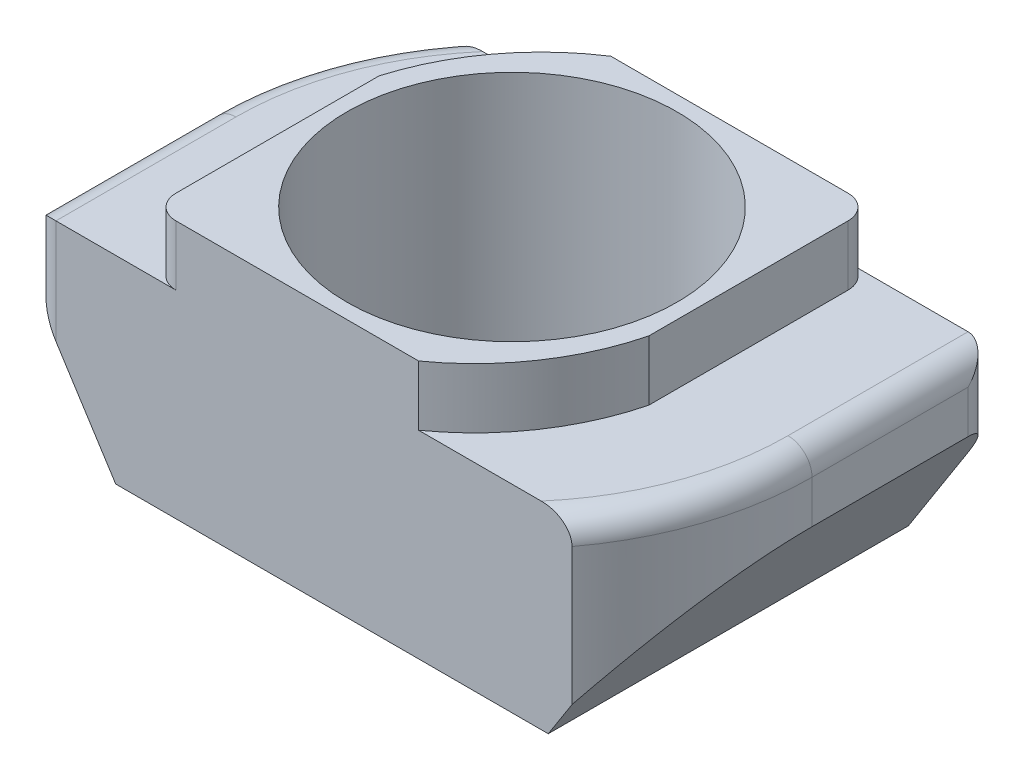
from build123d import *

# Parameters (mm, degrees)
BOSS_EXTRUDE1_DEPTH = 3.3
BOSS_EXTRUDE2_DEPTH = 1
SKETCH4_R           = 2.75
CUT_EXTRUDE1_DEPTH  = 5.3
CUT_EXTRUDE2_DEPTH  = 7
FILLET1_R           = 0.4


with BuildPart() as part:
    # Sketch1 → Boss-Extrude1 (new body)
    with BuildSketch(Plane(origin=(0, 0, 0), x_dir=(1, 0, 0), z_dir=(0, 1, 0))):
        with BuildLine():
            Line((-5, -3), (4, -3))
            ThreePointArc((4, -3), (4.74341641, -1.581139071), (5, -5.07e-07))
            Line((5, -5.07e-07), (5, 3))
            Line((5, 3), (-4, 3))
            ThreePointArc((-4, 3), (-4.74341641, 1.581139071), (-5, 5.07e-07))
            Line((-5, 5.07e-07), (-5, -3))
        make_face()
    extrude(amount=BOSS_EXTRUDE1_DEPTH)

    # Sketch3 → Boss-Extrude2 (add)
    with BuildSketch(Plane(origin=(0, 3.3, 0), x_dir=(1, 0, 0), z_dir=(0, 1, 0))):
        with BuildLine():
            Line((-3, -3), (1.443496021, -3))
            ThreePointArc((1.443496021, -3), (2.424601601, -1.998754321), (3, -0.720482929))
            Line((3, -0.720482929), (3, 3))
            Line((3, 3), (-1.352396976, 3))
            ThreePointArc((-1.352396976, 3), (-2.373272189, 2.039336237), (-3, 0.785433003))
            Line((-3, 0.785433003), (-3, -3))
        make_face()
    extrude(amount=BOSS_EXTRUDE2_DEPTH)

    # Sketch4 → Cut-Extrude1 (cut, through all)
    with BuildSketch(Plane(origin=(0, 4.3, 0), x_dir=(1, 0, 0), z_dir=(0, 1, 0))):
        Circle(SKETCH4_R)
    extrude(amount=-CUT_EXTRUDE1_DEPTH, mode=Mode.SUBTRACT)

    # Sketch5 → Cut-Extrude2 (cut, through all)
    with BuildSketch(Plane.XY.offset(3)):
        Polygon((4, 0), (5, 0), (5, 2.185994227), (3.604159787, 0), align=None)
        Polygon((-5, 0), (-3.604159787, 0), (-5, 2.185994227), align=None)
    extrude(amount=-CUT_EXTRUDE2_DEPTH, mode=Mode.SUBTRACT)

    # Fillet1
    fillet1_edges = [part.edges().sort_by_distance(p)[0] for p in [
        (-5, 2.742997113, 3),
        (5, 2.742997113, -3),
        (-4.74341641, 3.3, -1.581139071),
        (-5, 3.3, 1.499999746),
        (3, 3.8, -3),
        (4.74341641, 3.3, 1.581139071),
        (-3, 3.8, 3),
        (5, 3.3, -1.499999746),
    ]]
    fillet(fillet1_edges, radius=FILLET1_R)


solid = part.part
